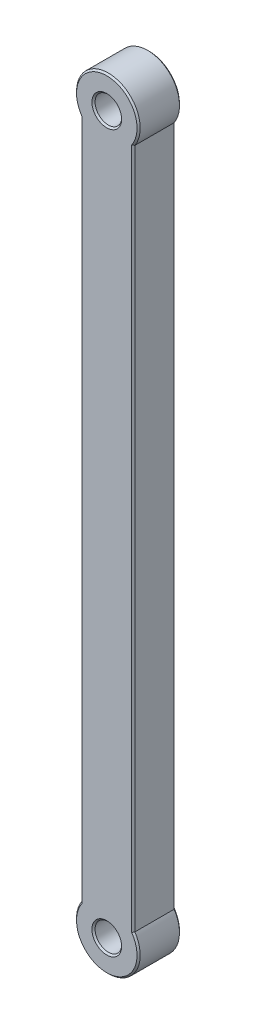
from build123d import *

# Parameters (mm, degrees)
EXTRUDE_1_DEPTH     = 8
SKETCH_2_R          = 6
EXTRUDE_2_DEPTH     = 8
SKETCH_3_R          = 2.5
CUT_EXTRUDE_1_DEPTH = 9
CHAMFER_1_SIZE      = 0.3


with BuildPart() as part:
    # 草图1 → 凸台-拉伸1 (new body)
    with BuildSketch(Plane.XY):
        with BuildLine():
            Line((-5, 0), (-5, 135))
            ThreePointArc((-5, 135), (0, 140), (5, 135))
            Line((5, 135), (5, 0))
            ThreePointArc((5, 0), (0, -5), (-5, 0))
        make_face()
    extrude(amount=EXTRUDE_1_DEPTH)

    # 草图2 → 凸台-拉伸2 (add)
    with BuildSketch(Plane.XY):
        Circle(SKETCH_2_R)
        with Locations((0, 135)):
            Circle(SKETCH_2_R)
    extrude(amount=EXTRUDE_2_DEPTH)

    # 草图3 → 切除-拉伸1 (cut, through all)
    with BuildSketch(Plane(origin=(0, 0, 0), x_dir=(-1, 0, 0), z_dir=(0, 0, -1))):
        with Locations((0, 135)):
            Circle(SKETCH_3_R)
        Circle(SKETCH_3_R)
    extrude(amount=-CUT_EXTRUDE_1_DEPTH, mode=Mode.SUBTRACT)

    # 倒角1
    chamfer_1_edges = [part.edges().sort_by_distance(p)[0] for p in [
        (5, 67.5, 0),
        (5, 67.5, 8),
        (0, -6, 8),
        (0, -6, 0),
        (-5, 67.5, 0),
        (-5, 67.5, 8),
        (0, 141, 0),
        (0, 141, 8),
        (2.5, 135, 8),
        (2.5, 135, 0),
        (2.5, 0, 8),
        (2.5, 0, 0),
    ]]
    chamfer(chamfer_1_edges, length=CHAMFER_1_SIZE)


solid = part.part
